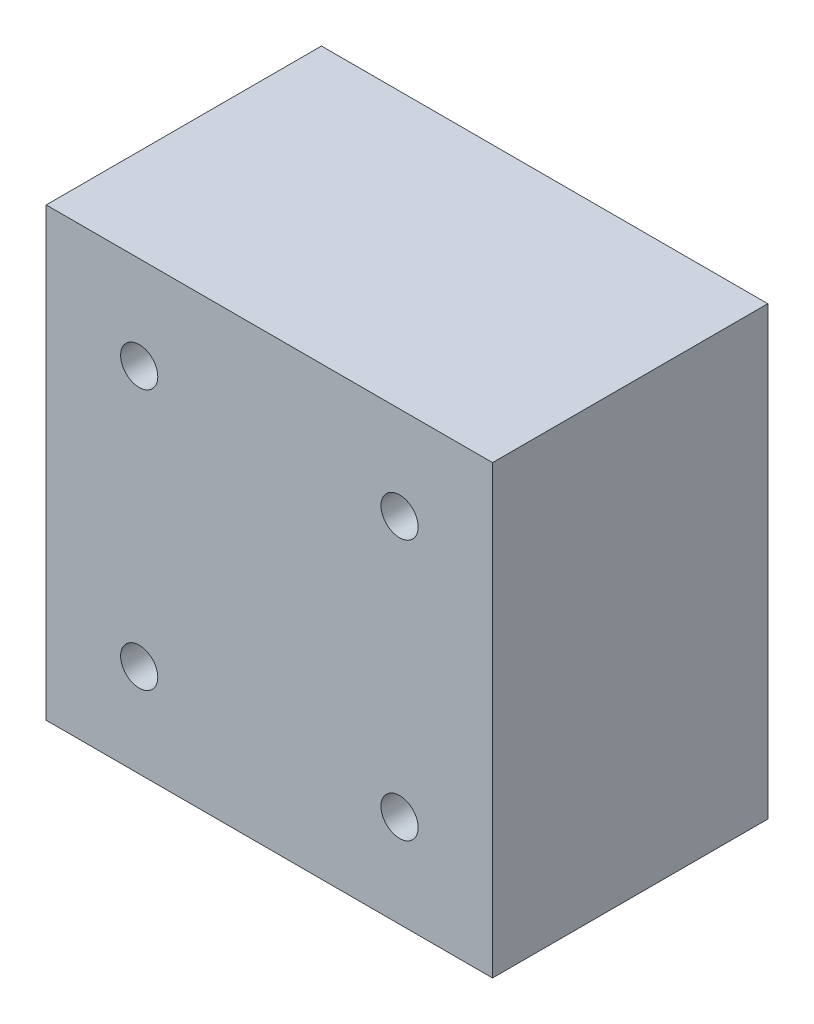
from build123d import *

# Parameters (mm, degrees)
SKETCH1_W           = 60
SKETCH1_H           = 60
BOSS_EXTRUDE1_DEPTH = 37
SKETCH2_R           = 2.5
CUT_EXTRUDE1_DEPTH  = 60


with BuildPart() as part:
    # Sketch1 → Boss-Extrude1 (new body)
    with BuildSketch(Plane.XY):
        Rectangle(SKETCH1_W, SKETCH1_H)
    extrude(amount=BOSS_EXTRUDE1_DEPTH)

    # Sketch2 → Cut-Extrude1 (cut)
    with BuildSketch(Plane.XY.offset(37)):
        with Locations((-17.5, 17.5)):
            Circle(SKETCH2_R)
        with Locations((17.5, 17.5)):
            Circle(SKETCH2_R)
        with Locations((17.5, -17.5)):
            Circle(SKETCH2_R)
        with Locations((-17.5, -17.5)):
            Circle(SKETCH2_R)
    extrude(amount=-CUT_EXTRUDE1_DEPTH, mode=Mode.SUBTRACT)


solid = part.part
